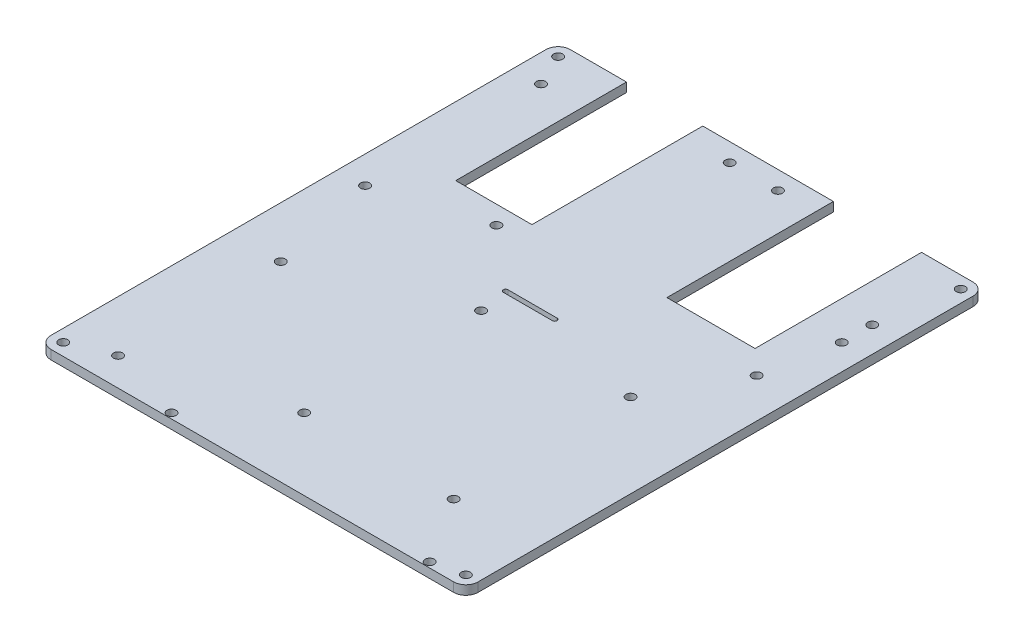
from build123d import *

# Parameters (mm, degrees)
SKETCH1_R           = 1.5
BOSS_EXTRUDE1_DEPTH = 3


with BuildPart() as part:
    # Sketch1 → Boss-Extrude1 (new body)
    with BuildSketch(Plane(origin=(0, 0, 0), x_dir=(1, 0, 0), z_dir=(0, 1, 0))):
        with BuildLine():
            Line((-4, 0), (-136, 0))
            ThreePointArc((-136, 0), (-138.828427125, 1.171572875), (-140, 4))
            Line((-140, 4), (-140, 166.25343074))
            ThreePointArc((-140, 166.25343074), (-138.828427125, 169.081857865), (-136, 170.25343074))
            Line((-136, 170.25343074), (-117.588107797, 170.25343074))
            Line((-117.588107797, 170.25343074), (-117.588107797, 114.261134971))
            Line((-117.588107797, 114.261134971), (-92.588107797, 114.261134971))
            Line((-92.588107797, 114.261134971), (-92.588107797, 170.25343074))
            Line((-92.588107797, 170.25343074), (-49.754336385, 170.25343074))
            Line((-49.754336385, 170.25343074), (-49.754336385, 115.66527195))
            Line((-49.754336385, 115.66527195), (-20.860369091, 115.66527195))
            Line((-20.860369091, 115.66527195), (-20.860369091, 170.25343074))
            Line((-20.860369091, 170.25343074), (-4, 170.25343074))
            ThreePointArc((-4, 170.25343074), (-1.171572875, 169.081857865), (0, 166.25343074))
            Line((0, 166.25343074), (0, 4))
            ThreePointArc((0, 4), (-1.171572875, 1.171572875), (-4, 0))
        make_face()
        with Locations((-136, 166.25343074)):
            Circle(SKETCH1_R, mode=Mode.SUBTRACT)
        with Locations((-4, 166.25343074)):
            Circle(SKETCH1_R, mode=Mode.SUBTRACT)
        with Locations((-136, 4)):
            Circle(SKETCH1_R, mode=Mode.SUBTRACT)
        with Locations((-4, 4)):
            Circle(SKETCH1_R, mode=Mode.SUBTRACT)
        with Locations((-8.360369091, 141.5902664)):
            Circle(SKETCH1_R, mode=Mode.SUBTRACT)
        with Locations((-8.360369091, 131.5902664)):
            Circle(SKETCH1_R, mode=Mode.SUBTRACT)
        with Locations((-123.265486726, 62.577470458)):
            Circle(SKETCH1_R, mode=Mode.SUBTRACT)
        with Locations((-123.265486726, 9.24694437)):
            Circle(SKETCH1_R, mode=Mode.SUBTRACT)
        with Locations((-61.946271424, 164.25343074)):
            Circle(SKETCH1_R, mode=Mode.SUBTRACT)
        with Locations((-77.75445726, 164.25343074)):
            Circle(SKETCH1_R, mode=Mode.SUBTRACT)
        with Locations((-131.022006432, 155.660698945)):
            Circle(SKETCH1_R, mode=Mode.SUBTRACT)
        with Locations((-131.022006432, 97.992651369)):
            Circle(SKETCH1_R, mode=Mode.SUBTRACT)
        with Locations((-27.5, 81.5)):
            Circle(SKETCH1_R, mode=Mode.SUBTRACT)
        with Locations((-76.5, 81.5)):
            Circle(SKETCH1_R, mode=Mode.SUBTRACT)
        with Locations((-27.5, 23.5)):
            Circle(SKETCH1_R, mode=Mode.SUBTRACT)
        with Locations((-76.5, 23.5)):
            Circle(SKETCH1_R, mode=Mode.SUBTRACT)
        with Locations((-98.25, 108.25)):
            Circle(SKETCH1_R, mode=Mode.SUBTRACT)
        with Locations((-12.919798313, 108.25)):
            Circle(SKETCH1_R, mode=Mode.SUBTRACT)
        with Locations((-98.25, 1.75)):
            Circle(SKETCH1_R, mode=Mode.SUBTRACT)
        with Locations((-13.615959215, 1.75)):
            Circle(SKETCH1_R, mode=Mode.SUBTRACT)
        with BuildLine():
            Line((-78.053728576, 91.841911577), (-61.946271424, 91.841911577))
            ThreePointArc((-61.946271424, 91.841911577), (-61.196519269, 91.092159423), (-61.946271424, 90.342407268))
            Line((-61.946271424, 90.342407268), (-78.053728576, 90.342407268))
            ThreePointArc((-78.053728576, 90.342407268), (-78.803480731, 91.092159423), (-78.053728576, 91.841911577))
        make_face(mode=Mode.SUBTRACT)
    extrude(amount=BOSS_EXTRUDE1_DEPTH)


solid = part.part
